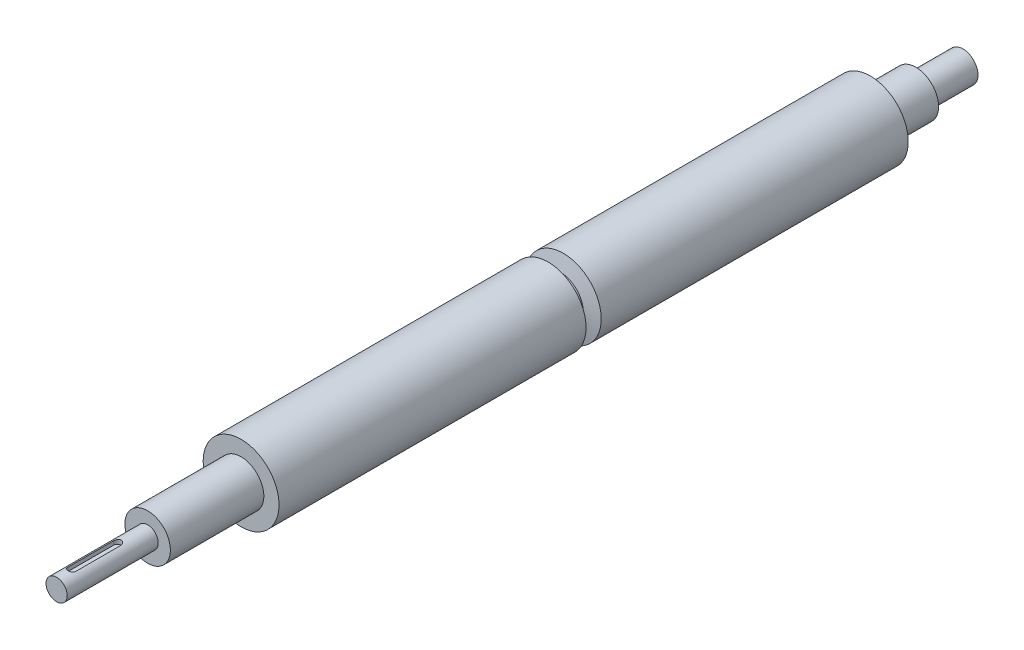
from build123d import *

# Parameters (mm, degrees)
ESQUISSE1_R             = 7
BOSS_EXTRU_1_DEPTH      = 60
ESQUISSE2_R             = 15
BOSS_EXTRU_2_DEPTH      = 61.6
ESQUISSE3_R             = 25
BOSS_EXTRU_3_DEPTH      = 414.8
ESQUISSE4_R             = 15
BOSS_EXTRU_4_DEPTH      = 30
ESQUISSE5_R             = 10
BOSS_EXTRU_5_DEPTH      = 31
ENL_V_MAT_EXTRU_1_DEPTH = 2.96


with BuildPart() as part:
    # Esquisse1 → Boss.-Extru.1 (new body)
    with BuildSketch(Plane.XY):
        Circle(ESQUISSE1_R)
    extrude(amount=BOSS_EXTRU_1_DEPTH)

    # Esquisse2 → Boss.-Extru.2 (add)
    with BuildSketch(Plane(origin=(0, 0, 0), x_dir=(-1, 0, 0), z_dir=(0, 0, -1))):
        Circle(ESQUISSE2_R)
    extrude(amount=BOSS_EXTRU_2_DEPTH)

    # Esquisse3 → Boss.-Extru.3 (add)
    with BuildSketch(Plane(origin=(0, 0, -61.6), x_dir=(-1, 0, 0), z_dir=(0, 0, -1))):
        Circle(ESQUISSE3_R)
    extrude(amount=BOSS_EXTRU_3_DEPTH)

    # Esquisse4 → Boss.-Extru.4 (add)
    with BuildSketch(Plane(origin=(0, 0, -476.4), x_dir=(-1, 0, 0), z_dir=(0, 0, -1))):
        Circle(ESQUISSE4_R)
    extrude(amount=BOSS_EXTRU_4_DEPTH)

    # Esquisse5 → Boss.-Extru.5 (add)
    with BuildSketch(Plane(origin=(0, 0, -506.4), x_dir=(-1, 0, 0), z_dir=(0, 0, -1))):
        Circle(ESQUISSE5_R)
    extrude(amount=BOSS_EXTRU_5_DEPTH)

    # Esquisse7 → Enlèv. mat.-Extru.1 (cut)
    with BuildSketch(Plane(origin=(0, 7, 0), x_dir=(1, 0, 0), z_dir=(0, 1, 0))):
        with BuildLine():
            Line((-2.5, -50), (-2.5, -20))
            ThreePointArc((-2.5, -20), (0, -17.5), (2.5, -20))
            Line((2.5, -20), (2.5, -50))
            ThreePointArc((2.5, -50), (0, -52.5), (-2.5, -50))
        make_face()
    extrude(amount=-ENL_V_MAT_EXTRU_1_DEPTH, mode=Mode.SUBTRACT)

    # Esquisse8 → Enlèvement de matière-Révolution1 (revolve, cut)
    with BuildSketch(Plane(origin=(0, 0, 0), x_dir=(0, 0, -1), z_dir=(1, 0, 0)), mode=Mode.PRIVATE) as enl_vement_de_mati_re_r_volution1_sk:
        Polygon((266, 15.202041029), (264, 25), (274, 25), (272, 15.202041029), align=None)
    revolve(enl_vement_de_mati_re_r_volution1_sk.sketch.rotate(Axis((0, 0, 0), (0, 0, -1)), 90), axis=Axis((0, 0, 0), (0, 0, -1)), mode=Mode.SUBTRACT)  # turned: the seam where the file's is


solid = part.part
